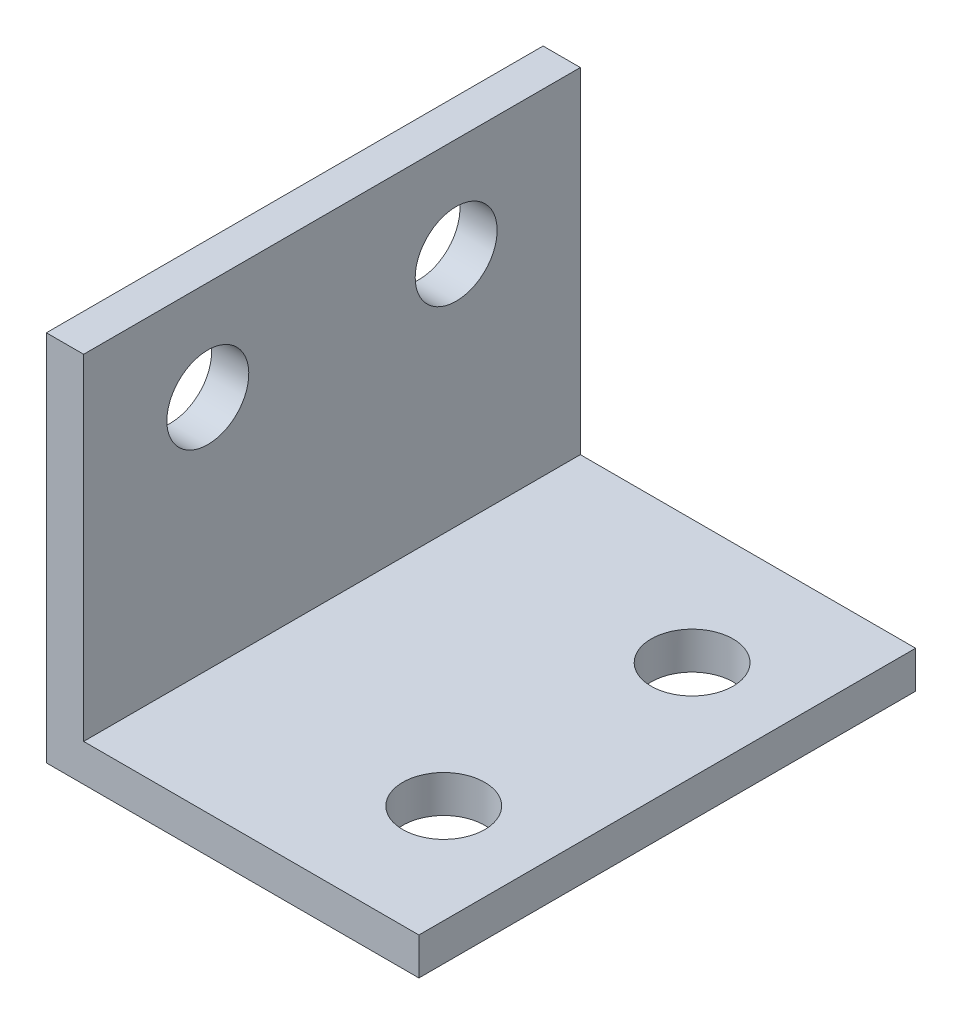
from build123d import *

# Parameters (mm, degrees)
EXTRUDE_1_DEPTH     = 40
SKETCH_2_R          = 3.3
CUT_EXTRUDE_1_DEPTH = 40
SKETCH_3_R          = 3.3
CUT_EXTRUDE_2_DEPTH = 40


with BuildPart() as part:
    # 草图1 → 凸台-拉伸1 (new body)
    with BuildSketch(Plane.XY):
        Polygon((0, 0), (0, 30), (3, 30), (3, 3), (30, 3), (30, 0), align=None)
    extrude(amount=EXTRUDE_1_DEPTH)

    # 草图2 → 切除-拉伸1 (cut)
    with BuildSketch(Plane.ZY):
        with Locations((10, 22)):
            Circle(SKETCH_2_R)
        with Locations((30, 22)):
            Circle(SKETCH_2_R)
    extrude(amount=-CUT_EXTRUDE_1_DEPTH, mode=Mode.SUBTRACT)

    # 草图3 → 切除-拉伸2 (cut)
    with BuildSketch(Plane.XZ):
        with Locations((22, 30)):
            Circle(SKETCH_3_R)
        with Locations((22, 10)):
            Circle(SKETCH_3_R)
    extrude(amount=-CUT_EXTRUDE_2_DEPTH, mode=Mode.SUBTRACT)


solid = part.part
